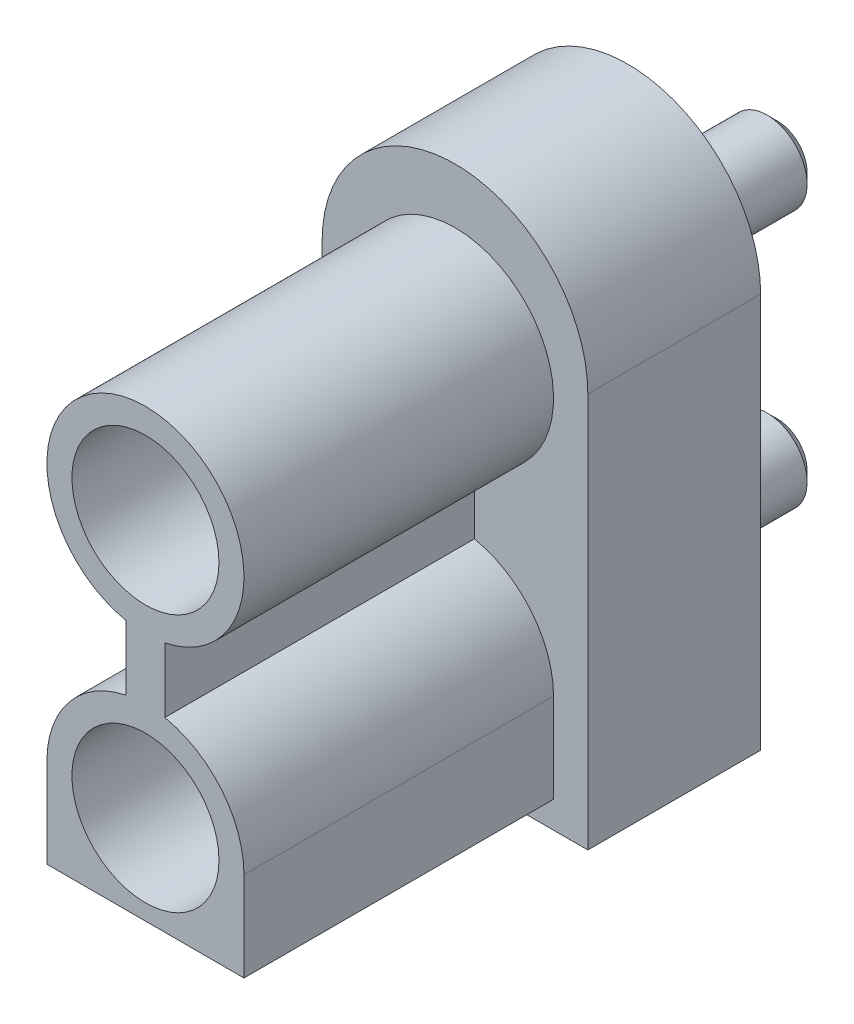
from build123d import *

# Parameters (mm, degrees)
SALIENTE_EXTRUIR1_DEPTH = 3.35
CROQUIS2_R              = 0.775
SALIENTE_EXTRUIR2_DEPTH = 2.9
CHAFL_N1_SIZE           = 0.2
CROQUIS3_R              = 1.425
SALIENTE_EXTRUIR3_DEPTH = 6


with BuildPart() as part:
    # Croquis1 → Saliente-Extruir1 (new body)
    with BuildSketch(Plane.XY):
        with BuildLine():
            Line((-2.575, 7.655), (-2.575, 0))
            Line((-2.575, 0), (2.575, 0))
            Line((2.575, 0), (2.575, 7.655))
            ThreePointArc((2.575, 7.655), (0, 10.23), (-2.575, 7.655))
        make_face()
    extrude(amount=SALIENTE_EXTRUIR1_DEPTH)

    # Croquis2 → Saliente-Extruir2 (add)
    with BuildSketch(Plane(origin=(0, 0, 0), x_dir=(-1, 0, 0), z_dir=(0, 0, -1))):
        with Locations((0, 7.25)):
            Circle(CROQUIS2_R)
        with Locations((0, 2.25)):
            Circle(CROQUIS2_R)
    extrude(amount=SALIENTE_EXTRUIR2_DEPTH)

    # Chaflán1
    chafl_n1_edges = [part.edges().sort_by_distance(p)[0] for p in [
        (0.775, 7.25, -2.9),
        (0.775, 2.25, -2.9),
    ]]
    chamfer(chafl_n1_edges, length=CHAFL_N1_SIZE)

    # Croquis3 → Saliente-Extruir3 (add)
    with BuildSketch(Plane.XY.offset(3.35)):
        with BuildLine():
            Line((-1.91, 2.25), (-1.91, 0.51859855))
            Line((-1.91, 0.51859855), (1.91, 0.51859855))
            Line((1.91, 0.51859855), (1.91, 2.25))
            ThreePointArc((1.91, 2.25), (1.47721867, 3.460753897), (0.375, 4.122825406))
            Line((0.375, 4.122825406), (0.375, 5.377174594))
            ThreePointArc((0.375, 5.377174594), (0, 9.16), (-0.375, 5.377174594))
            Line((-0.375, 5.377174594), (-0.375, 4.122825406))
            ThreePointArc((-0.375, 4.122825406), (-1.47721867, 3.460753897), (-1.91, 2.25))
        make_face()
        with Locations((0, 2.25)):
            Circle(CROQUIS3_R, mode=Mode.SUBTRACT)
        with Locations((0, 7.25)):
            Circle(CROQUIS3_R, mode=Mode.SUBTRACT)
    extrude(amount=SALIENTE_EXTRUIR3_DEPTH)


solid = part.part
